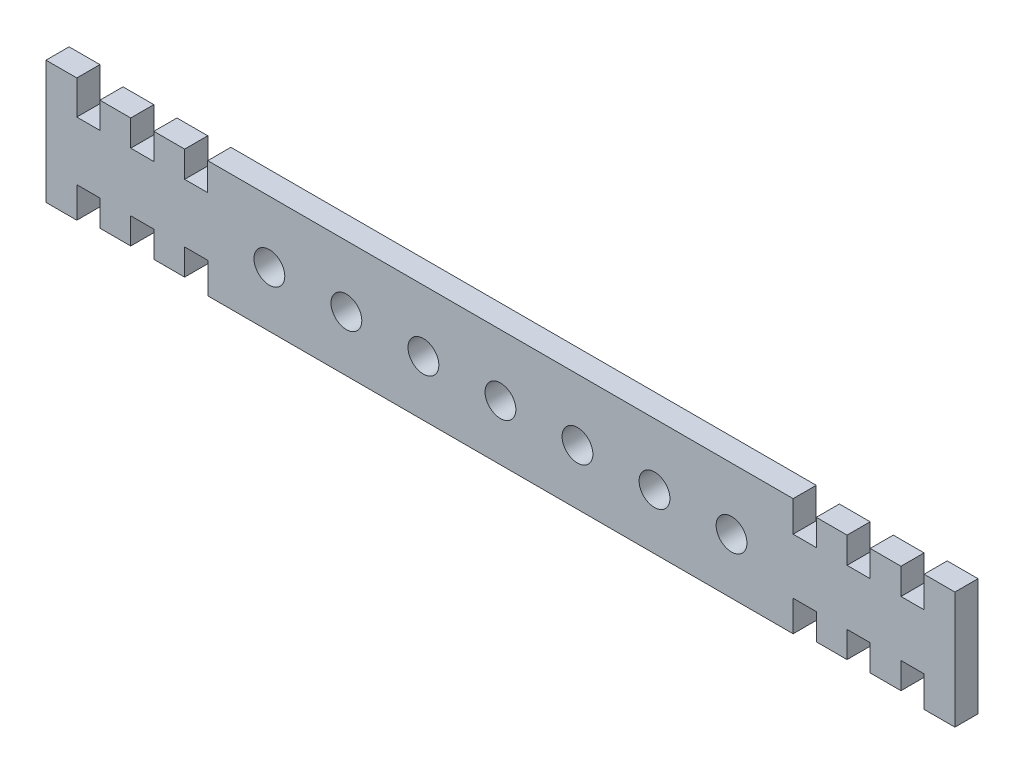
from build123d import *

# Parameters (mm, degrees)
SKETCH_1_R      = 1
EXTRUDE_1_DEPTH = 1.5


with BuildPart() as part:
    # 草图1 → 凸台-拉伸1 (new body)
    with BuildSketch(Plane.XY):
        Polygon((-19.000504276, 4), (18.999495724, 4), (18.999495724, 2), (20.5, 2), (20.5, 3.7), (22.499555553, 3.7), (22.499555553, 2), (24.00005983, 2), (24.00005983, 3.7), (25.999615383, 3.7), (25.999615383, 2), (27.50011966, 2), (27.50011966, 4), (29.499675213, 4), (29.499675213, -3.6), (27.5, -3.6), (27.5, -1.6), (26, -1.6), (26, -3.3), (24, -3.3), (24, -1.6), (22.5, -1.6), (22.5, -3.3), (20.5, -3.3), (20.5, -1.6), (19, -1.6), (19, -3.6), (-19, -3.6), (-19, -1.6), (-20.5, -1.6), (-20.5, -3.3), (-22.5, -3.3), (-22.5, -1.6), (-24, -1.6), (-24, -3.3), (-26, -3.3), (-26, -1.6), (-27.5, -1.6), (-27.5, -3.6), (-29.5, -3.6), (-29.5, 4.4), (-27.5, 4.4), (-27.5, 2.2), (-26, 2.2), (-26, 3.9), (-24, 3.9), (-24, 2.2), (-22.5, 2.2), (-22.5, 3.9), (-20.5, 3.9), (-20.5, 2.2), (-19.000504276, 2.2), align=None)
        Circle(SKETCH_1_R, mode=Mode.SUBTRACT)
        with Locations((5, 0)):
            Circle(SKETCH_1_R, mode=Mode.SUBTRACT)
        with Locations((10, 0)):
            Circle(SKETCH_1_R, mode=Mode.SUBTRACT)
        with Locations((15, 0)):
            Circle(SKETCH_1_R, mode=Mode.SUBTRACT)
        with Locations((-5, 0)):
            Circle(SKETCH_1_R, mode=Mode.SUBTRACT)
        with Locations((-10, 0)):
            Circle(SKETCH_1_R, mode=Mode.SUBTRACT)
        with Locations((-15, 0)):
            Circle(SKETCH_1_R, mode=Mode.SUBTRACT)
    extrude(amount=EXTRUDE_1_DEPTH)


solid = part.part
